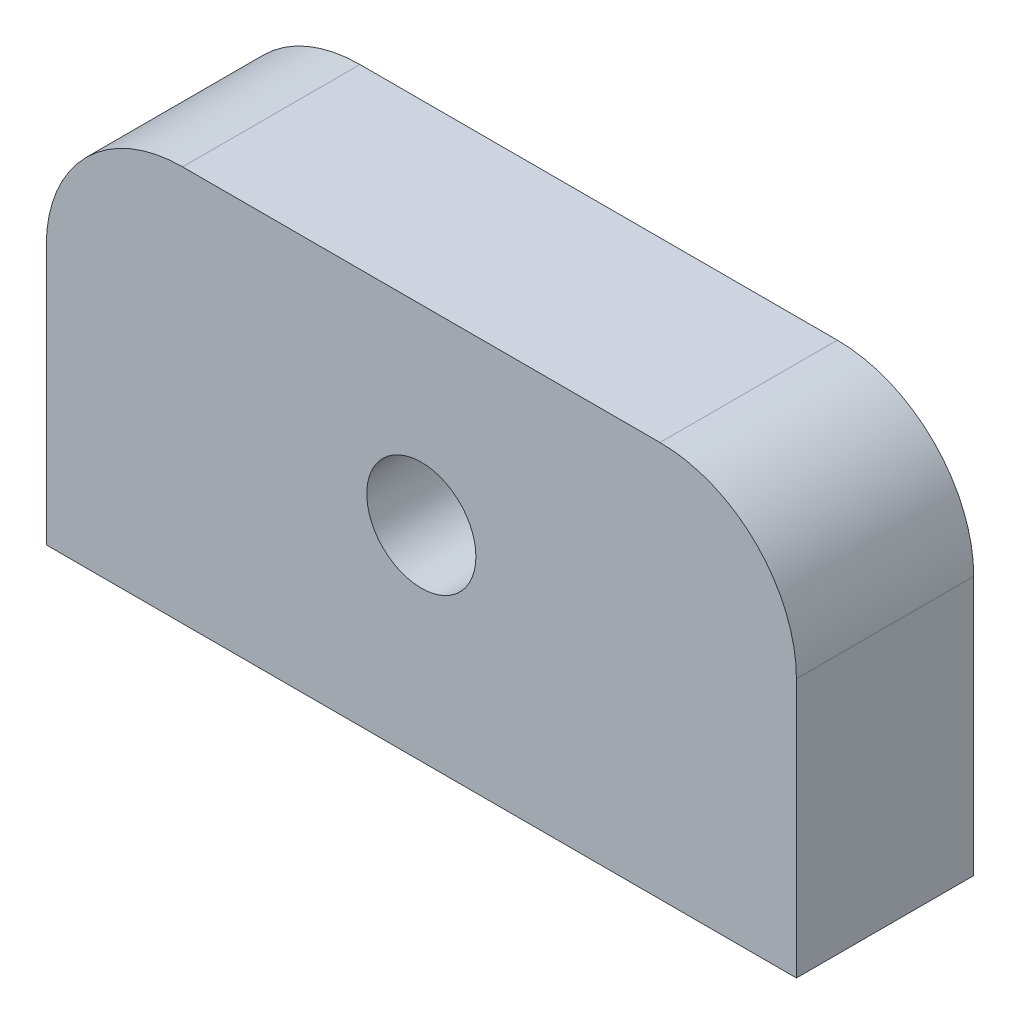
from build123d import *

# Parameters (mm, degrees)
SKETCH_1_W           = 55
SKETCH_1_H           = 29
EXTRUDE_1_DEPTH      = 13
SKETCH_2_OUTSIDE_W   = 69.704
SKETCH_2_OUTSIDE_H   = 43.704
SKETCH_2_OUTSIDE_W_2 = 55
SKETCH_2_OUTSIDE_H_2 = 29
SKETCH_2_OUTSIDE_R   = 4
CUT_EXTRUDE_1_DEPTH  = 13
FILLET_1_R           = 10


with BuildPart() as part:
    # 草图1 → 凸台-拉伸1 (new body)
    with BuildSketch(Plane.XY):
        with Locations((3.176056338, -2.774647887)):
            Rectangle(SKETCH_1_W, SKETCH_1_H)
    extrude(amount=EXTRUDE_1_DEPTH)

    # 草图2 outside → 切除-拉伸1 (cut)
    with BuildSketch(Plane.XY.offset(13)):
        with Locations((3.176, -2.775)):
            Rectangle(SKETCH_2_OUTSIDE_W, SKETCH_2_OUTSIDE_H)
        with Locations((3.176056338, -2.774647887)):
            Rectangle(SKETCH_2_OUTSIDE_W_2, SKETCH_2_OUTSIDE_H_2, mode=Mode.SUBTRACT)
        with Locations((3.176056338, -2.274647887)):
            Circle(SKETCH_2_OUTSIDE_R)
    extrude(amount=-CUT_EXTRUDE_1_DEPTH, mode=Mode.SUBTRACT)

    # 圆角1
    fillet_1_edges = [part.edges().sort_by_distance(p)[0] for p in [
        (-24.323943662, 11.725352113, 6.5),
        (30.676056338, 11.725352113, 6.5),
    ]]
    fillet(fillet_1_edges, radius=FILLET_1_R)


solid = part.part
